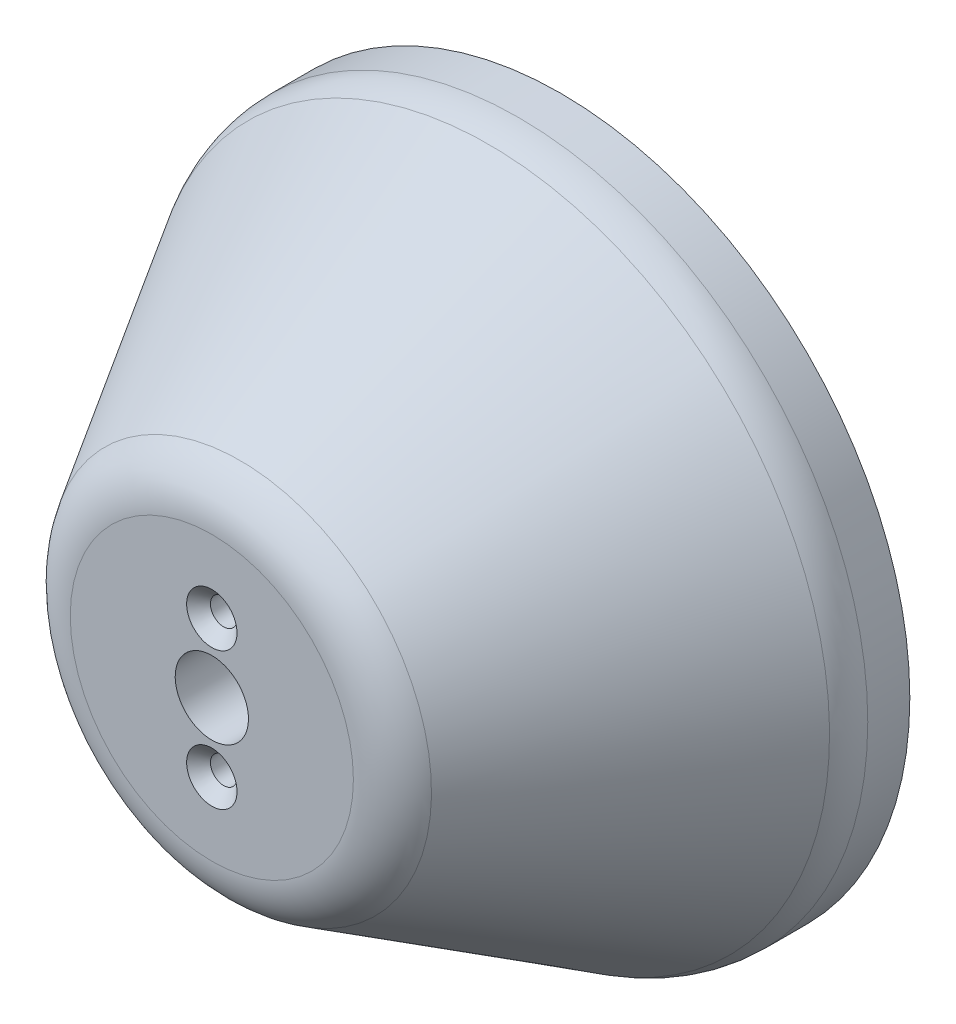
from build123d import *
from OCP.BRepFilletAPI import BRepFilletAPI_MakeChamfer

# Parameters (mm, degrees)
CSK_FOR_M2_5_FLAT_HEAD_MACHINE_SCREW1_D           = 2.9
CSK_FOR_M2_5_FLAT_HEAD_MACHINE_SCREW1_CSINK_D     = 5.5
CSK_FOR_M2_5_FLAT_HEAD_MACHINE_SCREW1_CSINK_ANGLE = 90
F_5_0_2055_DIAMETER_HOLE1_AT_2_COUNT              = 2
F_5_0_2055_DIAMETER_HOLE1_AT_2_PITCH              = 12.7
CHAMFER1_SIZE                                     = 4.7625
CHAMFER1_SIZE2                                    = 0.669325725
CIRPATTERN3_COUNT                                 = 4
CHAMFER1_OF_CIRPATTERN3_SIZE                      = 4.7625
CHAMFER1_OF_CIRPATTERN3_SIZE2                     = 0.669325725
FILLET10_R                                        = 6.35


with BuildPart() as part:
    # Sketch32 → Revolve8 (revolve)
    with BuildSketch(Plane(origin=(0, 0, 0), x_dir=(0, 0, -1), z_dir=(1, 0, 0))):
        Polygon((-38.1, 0), (-38.1, 19.05), (-6.35, 38.1), (0, 38.1), (0, 0), align=None)
    revolve(axis=Axis((0, 0, 0), (0, 0, 1)))

    # Sketch33 → Cut-Revolve1 (revolve, cut)
    with BuildSketch(Plane(origin=(0, 0, 0), x_dir=(0, 0, -1), z_dir=(1, 0, 0))):
        Polygon((-31.75, 14.2875), (-31.75, 4), (-38.1, 4), (-38.1, 0), (0, 0), (0, 14.2875), align=None)
    revolve(axis=Axis((0, 0, 0), (0, 0, 1)), mode=Mode.SUBTRACT)

    # CSK for M2.5 Flat Head Machine Screw1 (through all)
    with Locations(Plane.XY.offset(38.1)):
        with Locations((0, 7.5), (0, -7.5)):
            CounterSinkHole(CSK_FOR_M2_5_FLAT_HEAD_MACHINE_SCREW1_D / 2, CSK_FOR_M2_5_FLAT_HEAD_MACHINE_SCREW1_CSINK_D / 2, counter_sink_angle=CSK_FOR_M2_5_FLAT_HEAD_MACHINE_SCREW1_CSINK_ANGLE)

    # Sketch40 → 5 _0.2055_ Diameter Hole1 (revolve, cut)
    with BuildSketch(Plane(origin=(-6.35, 28.511429287, 0), x_dir=(0, 1, 0), z_dir=(1, 0, 0))):
        Polygon((0, 0), (0, 11.093156087), (2.60985, 9.525), (2.60985, 0), align=None)
    f_5_0_2055_diameter_hole1 = revolve(axis=Axis((-6.35, 28.511429287, -6.35), (0, 0, 1)), mode=Mode.SUBTRACT)

    # 5 _0.2055_ Diameter Hole1 at 2: 5 _0.2055_ Diameter Hole1 ×2
    with Locations(*[(i * F_5_0_2055_DIAMETER_HOLE1_AT_2_PITCH, 0, 0) for i in range(1, F_5_0_2055_DIAMETER_HOLE1_AT_2_COUNT)]):
        add(f_5_0_2055_diameter_hole1, mode=Mode.SUBTRACT)

    # Chamfer1: one chamfer whose edges measure the first distance from different faces: ONE call of the kernel's chamfer builder (chamfer() names one face for all edges)
    chamfer1_edges_1 = [part.edges().sort_by_distance(p)[0] for p in [
        (-6.35, 25.901579287, 0),
    ]]
    chamfer1_side_1 = [part.faces().sort_by_distance(p)[0] for p in [
        (-6.35, 25.901579287, 4.7625),
    ]]
    chamfer1_edges_2 = [part.edges().sort_by_distance(p)[0] for p in [
        (6.35, 25.901579287, 0),
    ]]
    chamfer1_side_2 = [part.faces().sort_by_distance(p)[0] for p in [
        (6.35, 25.901579287, 4.7625),
    ]]
    chamfer1 = BRepFilletAPI_MakeChamfer(part.part.solid().wrapped)
    for e in chamfer1_edges_1:
        chamfer1.Add(CHAMFER1_SIZE, CHAMFER1_SIZE2, e.wrapped, chamfer1_side_1[0].wrapped)  # the first distance lies on this face
    for e in chamfer1_edges_2:
        chamfer1.Add(CHAMFER1_SIZE, CHAMFER1_SIZE2, e.wrapped, chamfer1_side_2[0].wrapped)  # the first distance lies on this face
    add(Compound.cast(chamfer1.Shape()), mode=Mode.REPLACE)

    # CirPattern3: 5 _0.2055_ Diameter Hole1 ×4 about axis
    cirpattern3_axis = Axis((0, 0, 0), (0, 0, -1))
    for i in range(1, CIRPATTERN3_COUNT):
        add(f_5_0_2055_diameter_hole1.rotate(cirpattern3_axis, i * 360 / CIRPATTERN3_COUNT), mode=Mode.SUBTRACT)

    # CirPattern3 copy 1 sketch → CirPattern3 copy 1 (revolve, cut)
    with BuildSketch(Plane(origin=(28.511429287, -6.35, 0), x_dir=(1, 0, 0), z_dir=(0, -1, 0))):
        Polygon((0, 0), (0, 11.093156087), (2.60985, 9.525), (2.60985, 0), align=None)
    revolve(axis=Axis((28.511429287, -6.35, -6.35), (0, 0, 1)), mode=Mode.SUBTRACT)

    # CirPattern3 copy 2 sketch → CirPattern3 copy 2 (revolve, cut)
    with BuildSketch(Plane(origin=(-6.35, -28.511429287, 0), x_dir=(0, -1, 0), z_dir=(-1, 0, 0))):
        Polygon((0, 0), (0, 11.093156087), (2.60985, 9.525), (2.60985, 0), align=None)
    revolve(axis=Axis((-6.35, -28.511429287, -6.35), (0, 0, 1)), mode=Mode.SUBTRACT)

    # CirPattern3 copy 3 sketch → CirPattern3 copy 3 (revolve, cut)
    with BuildSketch(Plane(origin=(-28.511429287, 6.35, 0), x_dir=(-1, 0, 0), z_dir=(0, 1, 0))):
        Polygon((0, 0), (0, 11.093156087), (2.60985, 9.525), (2.60985, 0), align=None)
    revolve(axis=Axis((-28.511429287, 6.35, -6.35), (0, 0, 1)), mode=Mode.SUBTRACT)

    # Chamfer1 of CirPattern3: one chamfer whose edges measure the first distance from different faces: ONE call of the kernel's chamfer builder (chamfer() names one face for all edges)
    chamfer1_of_cirpattern3_edges_1 = [part.edges().sort_by_distance(p)[0] for p in [
        (25.901579287, 6.35, 0),
    ]]
    chamfer1_of_cirpattern3_side_1 = [part.faces().sort_by_distance(p)[0] for p in [
        (25.901579287, 6.35, 4.7625),
    ]]
    chamfer1_of_cirpattern3_edges_2 = [part.edges().sort_by_distance(p)[0] for p in [
        (25.901579287, -6.35, 0),
    ]]
    chamfer1_of_cirpattern3_side_2 = [part.faces().sort_by_distance(p)[0] for p in [
        (25.901579287, -6.35, 4.7625),
    ]]
    chamfer1_of_cirpattern3_edges_3 = [part.edges().sort_by_distance(p)[0] for p in [
        (6.35, -25.901579287, 0),
    ]]
    chamfer1_of_cirpattern3_side_3 = [part.faces().sort_by_distance(p)[0] for p in [
        (6.35, -25.901579287, 4.7625),
    ]]
    chamfer1_of_cirpattern3_edges_4 = [part.edges().sort_by_distance(p)[0] for p in [
        (-6.35, -25.901579287, 0),
    ]]
    chamfer1_of_cirpattern3_side_4 = [part.faces().sort_by_distance(p)[0] for p in [
        (-6.35, -25.901579287, 4.7625),
    ]]
    chamfer1_of_cirpattern3_edges_5 = [part.edges().sort_by_distance(p)[0] for p in [
        (-25.901579287, -6.35, 0),
    ]]
    chamfer1_of_cirpattern3_side_5 = [part.faces().sort_by_distance(p)[0] for p in [
        (-25.901579287, -6.35, 4.7625),
    ]]
    chamfer1_of_cirpattern3_edges_6 = [part.edges().sort_by_distance(p)[0] for p in [
        (-25.901579287, 6.35, 0),
    ]]
    chamfer1_of_cirpattern3_side_6 = [part.faces().sort_by_distance(p)[0] for p in [
        (-25.901579287, 6.35, 4.7625),
    ]]
    chamfer1_of_cirpattern3 = BRepFilletAPI_MakeChamfer(part.part.solid().wrapped)
    for e in chamfer1_of_cirpattern3_edges_1:
        chamfer1_of_cirpattern3.Add(CHAMFER1_OF_CIRPATTERN3_SIZE, CHAMFER1_OF_CIRPATTERN3_SIZE2, e.wrapped, chamfer1_of_cirpattern3_side_1[0].wrapped)  # the first distance lies on this face
    for e in chamfer1_of_cirpattern3_edges_2:
        chamfer1_of_cirpattern3.Add(CHAMFER1_OF_CIRPATTERN3_SIZE, CHAMFER1_OF_CIRPATTERN3_SIZE2, e.wrapped, chamfer1_of_cirpattern3_side_2[0].wrapped)  # the first distance lies on this face
    for e in chamfer1_of_cirpattern3_edges_3:
        chamfer1_of_cirpattern3.Add(CHAMFER1_OF_CIRPATTERN3_SIZE, CHAMFER1_OF_CIRPATTERN3_SIZE2, e.wrapped, chamfer1_of_cirpattern3_side_3[0].wrapped)  # the first distance lies on this face
    for e in chamfer1_of_cirpattern3_edges_4:
        chamfer1_of_cirpattern3.Add(CHAMFER1_OF_CIRPATTERN3_SIZE, CHAMFER1_OF_CIRPATTERN3_SIZE2, e.wrapped, chamfer1_of_cirpattern3_side_4[0].wrapped)  # the first distance lies on this face
    for e in chamfer1_of_cirpattern3_edges_5:
        chamfer1_of_cirpattern3.Add(CHAMFER1_OF_CIRPATTERN3_SIZE, CHAMFER1_OF_CIRPATTERN3_SIZE2, e.wrapped, chamfer1_of_cirpattern3_side_5[0].wrapped)  # the first distance lies on this face
    for e in chamfer1_of_cirpattern3_edges_6:
        chamfer1_of_cirpattern3.Add(CHAMFER1_OF_CIRPATTERN3_SIZE, CHAMFER1_OF_CIRPATTERN3_SIZE2, e.wrapped, chamfer1_of_cirpattern3_side_6[0].wrapped)  # the first distance lies on this face
    add(Compound.cast(chamfer1_of_cirpattern3.Shape()), mode=Mode.REPLACE)

    # Fillet10
    fillet10_edges = [part.edges().sort_by_distance(p)[0] for p in [
        (0, -38.1, 6.35),
        (0, -19.05, 38.1),
    ]]
    fillet(fillet10_edges, radius=FILLET10_R)


solid = part.part
